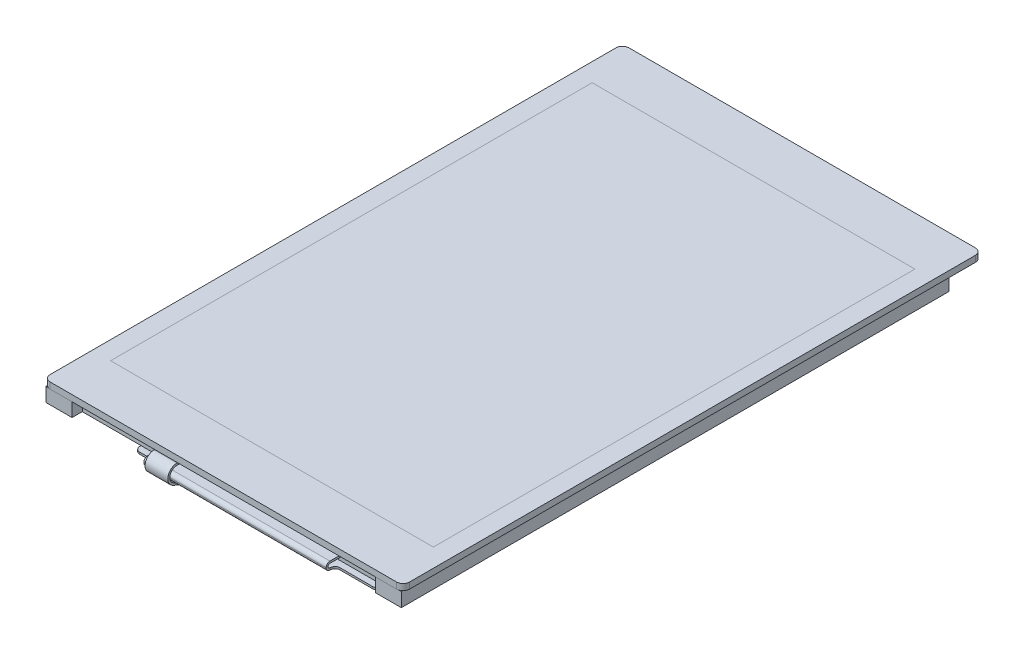
from build123d import *

# Parameters (mm, degrees)
LCD_BEZEL_DEPTH                 = 2.15
SKETCH2_W                       = 48.96
SKETCH2_H                       = 73.44
LCD_DEPTH                       = 0.1
SKETCH3_W                       = 49.56
SKETCH3_H                       = 73.94
CTP_BEZEL_DEPTH                 = 0.95
SKETCH4_W                       = 49.56
SKETCH4_H                       = 73.94
CTP_WINDOW_DEPTH                = 0.95
CTP_START                       = -27.59
CTP_FPC_FOLDED_EXTRUDE_DEPTH    = 30
SKETCH17_OUTSIDE_W              = 78.384
SKETCH17_OUTSIDE_H              = 113.574
CTP_FPC_FOLDED_ATTACHMENT_DEPTH = 0.3
SKETCH18_OUTSIDE_W              = 78.384
SKETCH18_OUTSIDE_H              = 113.574
CTP_FPC_FOLDED_END_DEPTH        = 0.3
SKETCH28_W                      = 22.56397635
SKETCH28_H                      = 16.140021554
SKETCH28_W_2                    = 17.009896394
SKETCH28_H_2                    = 16.522845441
CTP_FPC_FOLDED_CLEANUP_DEPTH    = 5.05
SKETCH24_W                      = 5
SKETCH24_H                      = 5
CTP_IC_FOLDED_DEPTH             = 0.9
LCD_START                       = 27.28
LCD_FPC_FOLDED_EXTRUDE_DEPTH    = 50
SKETCH26_OUTSIDE_W              = 78.394
SKETCH26_OUTSIDE_H              = 113.584
SKETCH26_OUTSIDE_W_2            = 28
SKETCH26_OUTSIDE_H_2            = 11.282317896
LCD_FPC_FOLDED_ATTACHMENT_DEPTH = 0.3
SKETCH27_OUTSIDE_W              = 78.394
SKETCH27_OUTSIDE_H              = 113.584
LCD_FPC_FOLDED_END_DEPTH        = 3.8
LCD_FPC_FOLDED_END_DEPTH_BACK   = 0.3
SKETCH29_W                      = 16.012596684
SKETCH29_H                      = 10.316486409
SKETCH29_W_2                    = 18.754120511
SKETCH29_H_2                    = 8.206348681
LCD_FPC_FOLDED_CLEANUP_DEPTH    = 0.6


with BuildPart() as part:
    # Sketch1 → LCD Bezel (new body)
    with BuildSketch(Plane(origin=(0, 0, 0), x_dir=(1, 0, 0), z_dir=(0, 1, 0))):
        Polygon((27.28, 42.035), (27.28, -42.035), (23.28, -42.035), (23.28, -40.465), (-23.28, -40.465), (-23.28, -42.035), (-27.28, -42.035), (-27.28, 42.035), align=None)
    extrude(amount=LCD_BEZEL_DEPTH)

    # Sketch2 → LCD (cut)
    with BuildSketch(Plane(origin=(0, 2.15, 0), x_dir=(1, 0, 0), z_dir=(0, 1, 0))):
        with Locations((0, 2.355)):
            Rectangle(SKETCH2_W, SKETCH2_H)
    extrude(amount=-LCD_DEPTH, mode=Mode.SUBTRACT)


with BuildPart() as body_2:
    # Sketch3 → CTP Bezel (new body)
    with BuildSketch(Plane(origin=(0, 2.15, 0), x_dir=(1, 0, 0), z_dir=(0, 1, 0))):
        with BuildLine():
            Line((-26.59, 46.79), (26.59, 46.79))
            ThreePointArc((26.59, 46.79), (27.297106781, 46.497106781), (27.59, 45.79))
            Line((27.59, 45.79), (27.59, -41.08))
            ThreePointArc((27.59, -41.08), (27.297106781, -41.787106781), (26.59, -42.08))
            Line((26.59, -42.08), (-26.59, -42.08))
            ThreePointArc((-26.59, -42.08), (-27.297106781, -41.787106781), (-27.59, -41.08))
            Line((-27.59, -41.08), (-27.59, 45.79))
            ThreePointArc((-27.59, 45.79), (-27.297106781, 46.497106781), (-26.59, 46.79))
        make_face()
        with Locations((0, 2.355)):
            Rectangle(SKETCH3_W, SKETCH3_H, mode=Mode.SUBTRACT)
    extrude(amount=CTP_BEZEL_DEPTH)


with BuildPart() as body_3:
    # Sketch4 → CTP Window (new body)
    with BuildSketch(Plane(origin=(0, 2.15, 0), x_dir=(1, 0, 0), z_dir=(0, 1, 0))):
        with Locations((0, 2.355)):
            Rectangle(SKETCH4_W, SKETCH4_H)
    extrude(amount=CTP_WINDOW_DEPTH)


with BuildPart() as body_4:
    # Sketch16 → CTP FPC Folded Extrude (new body)
    with BuildSketch(Plane(origin=(0, 0, 0), x_dir=(0, 0, -1), z_dir=(1, 0, 0)).offset(CTP_START)):
        with BuildLine():
            Line((-37.53, 2.15), (-42.08, 2.15))
            Line((-42.08, 2.15), (-42.18, 2.15))
            ThreePointArc((-42.18, 2.15), (-43.549037452, 1.042807879), (-42.752664219, -0.527519351))
            Line((-42.752664219, -0.527519351), (-39.607137612, -1.937541466))
            ThreePointArc((-39.607137612, -1.937541466), (-39.007445456, -2.133651683), (-38.38, -2.2))
            Line((-38.38, -2.2), (-18.999583084, -2.2))
            Line((-18.999583084, -2.2), (-18.999583084, -1.9))
            Line((-18.999583084, -1.9), (-38.38, -1.9))
            ThreePointArc((-38.38, -1.9), (-38.94470091, -1.840286515), (-39.484423851, -1.66378732))
            Line((-39.484423851, -1.66378732), (-42.629950458, -0.253765204))
            ThreePointArc((-42.629950458, -0.253765204), (-43.255672284, 0.980063334), (-42.18, 1.85))
            Line((-42.18, 1.85), (-42.08, 1.85))
            Line((-42.08, 1.85), (-37.53, 1.85))
            Line((-37.53, 1.85), (-37.53, 2.15))
        make_face()
    extrude(amount=CTP_FPC_FOLDED_EXTRUDE_DEPTH)

    # Sketch17 outside → CTP FPC Folded Attachment (cut)
    with BuildSketch(Plane.XZ.offset(-2.15)):
        with Locations((0, -1.605)):
            Rectangle(SKETCH17_OUTSIDE_W, SKETCH17_OUTSIDE_H)
        Polygon((-7.03, 48.454000558), (-7.03, 37.53), (-26.19, 37.53), (-26.19, 41.28), (-10.53, 41.28), (-10.53, 48.454000558), align=None, mode=Mode.SUBTRACT)
    extrude(amount=CTP_FPC_FOLDED_ATTACHMENT_DEPTH, mode=Mode.SUBTRACT)

    # Sketch18 outside → CTP FPC Folded End (cut)
    with BuildSketch(Plane.XZ.offset(2.2)):
        with Locations((0, -1.605)):
            Rectangle(SKETCH18_OUTSIDE_W, SKETCH18_OUTSIDE_H)
        with BuildLine():
            Line((-10.53, 49.501364097), (-10.53, 22.499583084))
            Line((-10.53, 22.499583084), (-9.53, 22.499583084))
            Line((-9.53, 22.499583084), (-9.53, 19.249583084))
            ThreePointArc((-9.53, 19.249583084), (-9.456776695, 19.072806389), (-9.28, 18.999583084))
            Line((-9.28, 18.999583084), (-6.28, 18.999583084))
            ThreePointArc((-6.28, 18.999583084), (-6.103223305, 19.072806389), (-6.03, 19.249583084))
            Line((-6.03, 19.249583084), (-6.03, 22.499583084))
            Line((-6.03, 22.499583084), (-2.53, 22.499583084))
            Line((-2.53, 22.499583084), (-2.53, 32.499583084))
            Line((-2.53, 32.499583084), (-7.03, 32.499583084))
            Line((-7.03, 32.499583084), (-7.03, 49.501364097))
            Line((-7.03, 49.501364097), (-10.53, 49.501364097))
        make_face(mode=Mode.SUBTRACT)
    extrude(amount=-CTP_FPC_FOLDED_END_DEPTH, mode=Mode.SUBTRACT)

    # Sketch28 → CTP FPC Folded Cleanup (cut, through all)
    with BuildSketch(Plane.XZ.offset(-1.85)):
        with Locations((-21.811988175, 40.846754759)):
            Rectangle(SKETCH28_W, SKETCH28_H)
        with Locations((1.474948197, 40.761005805)):
            Rectangle(SKETCH28_W_2, SKETCH28_H_2)
    extrude(amount=CTP_FPC_FOLDED_CLEANUP_DEPTH, mode=Mode.SUBTRACT)


with BuildPart() as body_5:
    # Sketch24 → CTP IC Folded (new body)
    with BuildSketch(Plane.XZ.offset(2.2)):
        with Locations((-6.53, 27.999583084)):
            Rectangle(SKETCH24_W, SKETCH24_H)
    extrude(amount=CTP_IC_FOLDED_DEPTH)


with BuildPart() as body_6:
    # Sketch25 → LCD FPC Folded Extrude (new body)
    with BuildSketch(Plane(origin=(0, 0, 0), x_dir=(0, 0, -1), z_dir=(1, 0, 0)).offset(LCD_START)):
        with BuildLine():
            Line((-39.465, 0.6), (-40.465, 0.6))
            Line((-40.465, 0.6), (-42.215, 0.6))
            ThreePointArc((-42.215, 0.6), (-42.420060967, 0.515060967), (-42.505, 0.31))
            Line((-42.505, 0.31), (-42.505, 0.29))
            ThreePointArc((-42.505, 0.29), (-42.420060967, 0.084939033), (-42.215, 0))
            Line((-42.215, 0), (-30.17606187, 0))
            Line((-30.17606187, 0), (-12.215, 0))
            ThreePointArc((-12.215, 0), (-11.601108636, -0.063482097), (-11.013198014, -0.251241738))
            Line((-11.013198014, -0.251241738), (-7.816801986, -1.648758262))
            ThreePointArc((-7.816801986, -1.648758262), (-7.228891364, -1.836517903), (-6.615, -1.9))
            Line((-6.615, -1.9), (2.002351526, -1.9))
            Line((2.002351526, -1.9), (2.002351526, -2.2))
            Line((2.002351526, -2.2), (-6.615, -2.2))
            ThreePointArc((-6.615, -2.2), (-7.2902805, -2.130169693), (-7.936982185, -1.923634089))
            Line((-7.936982185, -1.923634089), (-11.133378212, -0.526117564))
            ThreePointArc((-11.133378212, -0.526117564), (-11.662497773, -0.357133887), (-12.215, -0.3))
            Line((-12.215, -0.3), (-30.17606187, -0.3))
            Line((-30.17606187, -0.3), (-42.215, -0.3))
            ThreePointArc((-42.215, -0.3), (-42.632193001, -0.127193001), (-42.805, 0.29))
            Line((-42.805, 0.29), (-42.805, 0.31))
            ThreePointArc((-42.805, 0.31), (-42.632193001, 0.727193001), (-42.215, 0.9))
            Line((-42.215, 0.9), (-40.465, 0.9))
            Line((-40.465, 0.9), (-39.465, 0.9))
            Line((-39.465, 0.9), (-39.465, 0.6))
        make_face()
    extrude(amount=-LCD_FPC_FOLDED_EXTRUDE_DEPTH)

    # Sketch26 outside → LCD FPC Folded Attachment (cut)
    with BuildSketch(Plane(origin=(0, 0.9, 0), x_dir=(1, 0, 0), z_dir=(0, 1, 0))):
        with Locations((0, 1.605)):
            Rectangle(SKETCH26_OUTSIDE_W, SKETCH26_OUTSIDE_H)
        with Locations((2.5, -45.106158948)):
            Rectangle(SKETCH26_OUTSIDE_W_2, SKETCH26_OUTSIDE_H_2, mode=Mode.SUBTRACT)
    extrude(amount=-LCD_FPC_FOLDED_ATTACHMENT_DEPTH, mode=Mode.SUBTRACT)

    # Sketch27 outside → LCD FPC Folded End (cut, two sides)
    with BuildSketch(Plane.XZ.offset(0.3)) as lcd_fpc_folded_end_sk:
        with Locations((0, -1.605)):
            Rectangle(SKETCH27_OUTSIDE_W, SKETCH27_OUTSIDE_H)
        with BuildLine():
            Line((-10.25, 29.42606187), (-10.25, -1.752351526))
            ThreePointArc((-10.25, -1.752351526), (-10.176776695, -1.929128221), (-10, -2.002351526))
            Line((-10, -2.002351526), (10, -2.002351526))
            ThreePointArc((10, -2.002351526), (10.176776695, -1.929128221), (10.25, -1.752351526))
            Line((10.25, -1.752351526), (10.25, 29.42606187))
            ThreePointArc((10.25, 29.42606187), (10.469669914, 29.956391955), (11, 30.17606187))
            Line((11, 30.17606187), (22.25, 30.17606187))
            ThreePointArc((22.25, 30.17606187), (22.780330086, 30.395731784), (23, 30.92606187))
            Line((23, 30.92606187), (23, 40.67606187))
            ThreePointArc((23, 40.67606187), (22.780330086, 41.206391955), (22.25, 41.42606187))
            Line((22.25, 41.42606187), (17.25, 41.42606187))
            ThreePointArc((17.25, 41.42606187), (16.719669914, 41.645731784), (16.5, 42.17606187))
            Line((16.5, 42.17606187), (16.5, 50.399703005))
            Line((16.5, 50.399703005), (-11.5, 50.399703005))
            Line((-11.5, 50.399703005), (-11.5, 42.17606187))
            ThreePointArc((-11.5, 42.17606187), (-11.719669914, 41.645731784), (-12.25, 41.42606187))
            Line((-12.25, 41.42606187), (-13.5, 41.42606187))
            ThreePointArc((-13.5, 41.42606187), (-14.030330086, 41.206391955), (-14.25, 40.67606187))
            Line((-14.25, 40.67606187), (-14.25, 30.92606187))
            ThreePointArc((-14.25, 30.92606187), (-14.030330086, 30.395731784), (-13.5, 30.17606187))
            Line((-13.5, 30.17606187), (-11, 30.17606187))
            ThreePointArc((-11, 30.17606187), (-10.469669914, 29.956391955), (-10.25, 29.42606187))
        make_face(mode=Mode.SUBTRACT)
    extrude(amount=LCD_FPC_FOLDED_END_DEPTH, mode=Mode.SUBTRACT)
    extrude(lcd_fpc_folded_end_sk.sketch, amount=-LCD_FPC_FOLDED_END_DEPTH_BACK, mode=Mode.SUBTRACT)

    # Sketch29 → LCD FPC Folded Cleanup (cut)
    with BuildSketch(Plane.XZ.offset(-0.6)):
        with Locations((-19.506298342, 47.334305075)):
            Rectangle(SKETCH29_W, SKETCH29_H)
        with Locations((25.877060256, 46.279236211)):
            Rectangle(SKETCH29_W_2, SKETCH29_H_2)
    extrude(amount=LCD_FPC_FOLDED_CLEANUP_DEPTH, mode=Mode.SUBTRACT)


solid = Compound([part.part, body_2.part, body_3.part, body_4.part, body_5.part, body_6.part])
